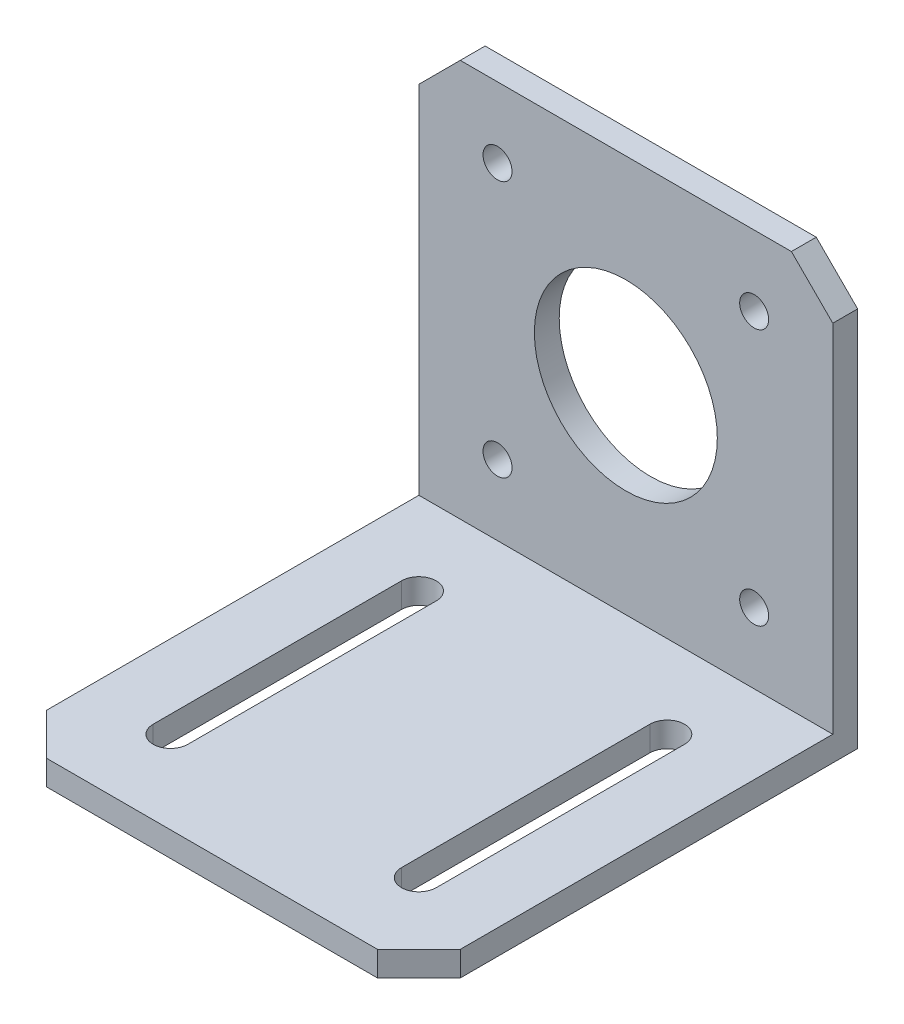
from build123d import *

# Parameters (mm, degrees)
BOSS_EXTRUDE1_DEPTH = 50
CUT_EXTRUDE1_REACH  = 5
SKETCH2_R           = 11.05
SKETCH2_R_2         = 1.75
CUT_EXTRUDE2_REACH  = 5
CHAMFER1_SIZE       = 5


with BuildPart() as part:
    # Sketch1 → Boss-Extrude1 (new body)
    with BuildSketch(Plane(origin=(0, 0, 0), x_dir=(0, 0, -1), z_dir=(1, 0, 0))):
        Polygon((0, 0), (0, 3), (50, 3), (50, 51), (53, 51), (53, 0), align=None)
    extrude(amount=-BOSS_EXTRUDE1_DEPTH)

    # Sketch2 → Cut-Extrude1 (cut, up to next)
    with BuildSketch(Plane.XY.offset(-50), mode=Mode.PRIVATE) as cut_extrude1_sk1:
        with Locations((-25, 27)):
            Circle(SKETCH2_R)
    cut_extrude1_tool1 = extrude(cut_extrude1_sk1.sketch, amount=-CUT_EXTRUDE1_REACH, mode=Mode.PRIVATE) & part.part
    add(cut_extrude1_tool1.solids().sort_by_distance((-25, 27, -50))[0], mode=Mode.SUBTRACT)
    # Sketch2 → Cut-Extrude1 (cut, up to next)
    with BuildSketch(Plane.XY.offset(-50), mode=Mode.PRIVATE) as cut_extrude1_sk2:
        with Locations((-40.5, 42.5)):
            Circle(SKETCH2_R_2)
    cut_extrude1_tool2 = extrude(cut_extrude1_sk2.sketch, amount=-CUT_EXTRUDE1_REACH, mode=Mode.PRIVATE) & part.part
    add(cut_extrude1_tool2.solids().sort_by_distance((-40.5, 42.5, -50))[0], mode=Mode.SUBTRACT)
    # Sketch2 → Cut-Extrude1 (cut, up to next)
    with BuildSketch(Plane.XY.offset(-50), mode=Mode.PRIVATE) as cut_extrude1_sk3:
        with Locations((-9.5, 42.5)):
            Circle(SKETCH2_R_2)
    cut_extrude1_tool3 = extrude(cut_extrude1_sk3.sketch, amount=-CUT_EXTRUDE1_REACH, mode=Mode.PRIVATE) & part.part
    add(cut_extrude1_tool3.solids().sort_by_distance((-9.5, 42.5, -50))[0], mode=Mode.SUBTRACT)
    # Sketch2 → Cut-Extrude1 (cut, up to next)
    with BuildSketch(Plane.XY.offset(-50), mode=Mode.PRIVATE) as cut_extrude1_sk4:
        with Locations((-9.5, 11.5)):
            Circle(SKETCH2_R_2)
    cut_extrude1_tool4 = extrude(cut_extrude1_sk4.sketch, amount=-CUT_EXTRUDE1_REACH, mode=Mode.PRIVATE) & part.part
    add(cut_extrude1_tool4.solids().sort_by_distance((-9.5, 11.5, -50))[0], mode=Mode.SUBTRACT)
    # Sketch2 → Cut-Extrude1 (cut, up to next)
    with BuildSketch(Plane.XY.offset(-50), mode=Mode.PRIVATE) as cut_extrude1_sk5:
        with Locations((-40.5, 11.5)):
            Circle(SKETCH2_R_2)
    cut_extrude1_tool5 = extrude(cut_extrude1_sk5.sketch, amount=-CUT_EXTRUDE1_REACH, mode=Mode.PRIVATE) & part.part
    add(cut_extrude1_tool5.solids().sort_by_distance((-40.5, 11.5, -50))[0], mode=Mode.SUBTRACT)

    # Sketch3 → Cut-Extrude2 (cut, up to next)
    with BuildSketch(Plane(origin=(0, 3, 0), x_dir=(1, 0, 0), z_dir=(0, 1, 0)), mode=Mode.PRIVATE) as cut_extrude2_sk1:
        with BuildLine():
            Line((-37.9, 40), (-37.9, 10))
            ThreePointArc((-37.9, 10), (-40, 7.9), (-42.1, 10))
            Line((-42.1, 10), (-42.1, 40))
            ThreePointArc((-42.1, 40), (-40, 42.1), (-37.9, 40))
        make_face()
    cut_extrude2_tool1 = extrude(cut_extrude2_sk1.sketch, amount=-CUT_EXTRUDE2_REACH, mode=Mode.PRIVATE) & part.part
    add(cut_extrude2_tool1.solids().sort_by_distance((-40, 3, -25))[0], mode=Mode.SUBTRACT)
    # Sketch3 → Cut-Extrude2 (cut, up to next)
    with BuildSketch(Plane(origin=(0, 3, 0), x_dir=(1, 0, 0), z_dir=(0, 1, 0)), mode=Mode.PRIVATE) as cut_extrude2_sk2:
        with BuildLine():
            Line((-12.1, 40), (-12.1, 10))
            ThreePointArc((-12.1, 10), (-10, 7.9), (-7.9, 10))
            Line((-7.9, 10), (-7.9, 40))
            ThreePointArc((-7.9, 40), (-10, 42.1), (-12.1, 40))
        make_face()
    cut_extrude2_tool2 = extrude(cut_extrude2_sk2.sketch, amount=-CUT_EXTRUDE2_REACH, mode=Mode.PRIVATE) & part.part
    add(cut_extrude2_tool2.solids().sort_by_distance((-10, 3, -25))[0], mode=Mode.SUBTRACT)

    # Chamfer1
    chamfer1_edges = [part.edges().sort_by_distance(p)[0] for p in [
        (-50, 51, -51.5),
        (-50, 1.5, 0),
        (0, 1.5, 0),
        (0, 51, -51.5),
    ]]
    chamfer(chamfer1_edges, length=CHAMFER1_SIZE)


solid = part.part
